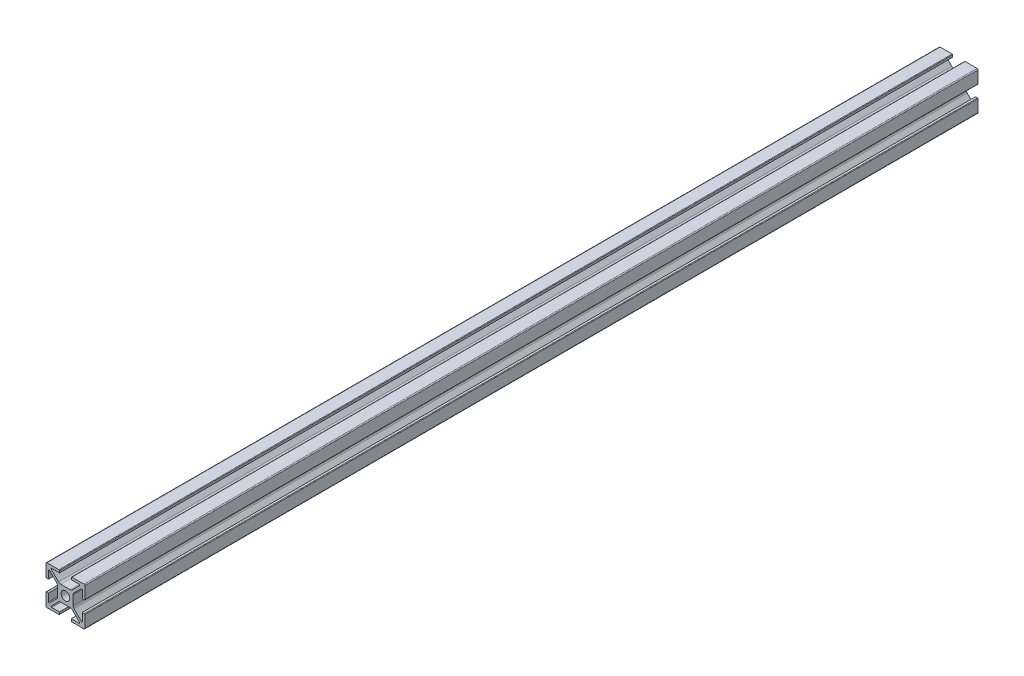
from build123d import *

# Parameters (mm, degrees)
ESBO_O11_R                                   = 2.25
QUADRADO_PF20_21_PERFIL_2020_T_SLOT_6M_DEPTH = 460


with BuildPart() as part:
    # Esboço11 → Quadrado PF20-21 - PERFIL 2020 T-SLOT 6MM(1) (new body)
    with BuildSketch(Plane(origin=(0, 0, 0), x_dir=(0, -1, 0), z_dir=(0, 0, 1))):
        with BuildLine():
            Line((8.187867966, -7.26862915), (4.439339828, -3.520101013))
            ThreePointArc((4.439339828, -3.520101013), (4.114180701, -3.033465989), (4, -2.459440841))
            Line((4, -2.459440841), (4, 2.459440841))
            ThreePointArc((4, 2.459440841), (4.114180701, 3.033465989), (4.439339828, 3.520101013))
            Line((4.439339828, 3.520101013), (8.187867966, 7.26862915))
            ThreePointArc((8.187867966, 7.26862915), (8.51480503, 7.333660975), (8.7, 7.056497116))
            Line((8.7, 7.056497116), (8.7, 3.05))
            Line((8.7, 3.05), (9.7, 3.05))
            ThreePointArc((9.7, 3.05), (9.912132034, 3.137867966), (10, 3.35))
            Line((10, 3.35), (10, 9.5))
            ThreePointArc((10, 9.5), (9.853553391, 9.853553391), (9.5, 10))
            Line((9.5, 10), (3.35, 10))
            ThreePointArc((3.35, 10), (3.137867966, 9.912132034), (3.05, 9.7))
            Line((3.05, 9.7), (3.05, 8.7))
            Line((3.05, 8.7), (7.056497116, 8.7))
            ThreePointArc((7.056497116, 8.7), (7.333660975, 8.51480503), (7.26862915, 8.187867966))
            Line((7.26862915, 8.187867966), (3.520101013, 4.439339828))
            ThreePointArc((3.520101013, 4.439339828), (3.033465989, 4.114180701), (2.459440841, 4))
            Line((2.459440841, 4), (-2.459440841, 4))
            ThreePointArc((-2.459440841, 4), (-3.033465989, 4.114180701), (-3.520101013, 4.439339828))
            Line((-3.520101013, 4.439339828), (-7.26862915, 8.187867966))
            ThreePointArc((-7.26862915, 8.187867966), (-7.333660975, 8.51480503), (-7.056497116, 8.7))
            Line((-7.056497116, 8.7), (-3.05, 8.7))
            Line((-3.05, 8.7), (-3.05, 9.7))
            ThreePointArc((-3.05, 9.7), (-3.137867966, 9.912132034), (-3.35, 10))
            Line((-3.35, 10), (-9.5, 10))
            ThreePointArc((-9.5, 10), (-9.853553391, 9.853553391), (-10, 9.5))
            Line((-10, 9.5), (-10, 3.35))
            ThreePointArc((-10, 3.35), (-9.912132034, 3.137867966), (-9.7, 3.05))
            Line((-9.7, 3.05), (-8.7, 3.05))
            Line((-8.7, 3.05), (-8.7, 7.056497116))
            ThreePointArc((-8.7, 7.056497116), (-8.51480503, 7.333660975), (-8.187867966, 7.26862915))
            Line((-8.187867966, 7.26862915), (-4.439339828, 3.520101013))
            ThreePointArc((-4.439339828, 3.520101013), (-4.114180701, 3.033465989), (-4, 2.459440841))
            Line((-4, 2.459440841), (-4, -2.459440841))
            ThreePointArc((-4, -2.459440841), (-4.114180701, -3.033465989), (-4.439339828, -3.520101013))
            Line((-4.439339828, -3.520101013), (-8.187867966, -7.26862915))
            ThreePointArc((-8.187867966, -7.26862915), (-8.51480503, -7.333660975), (-8.7, -7.056497116))
            Line((-8.7, -7.056497116), (-8.7, -3.05))
            Line((-8.7, -3.05), (-9.7, -3.05))
            ThreePointArc((-9.7, -3.05), (-9.912132034, -3.137867966), (-10, -3.35))
            Line((-10, -3.35), (-10, -9.5))
            ThreePointArc((-10, -9.5), (-9.853553391, -9.853553391), (-9.5, -10))
            Line((-9.5, -10), (-3.35, -10))
            ThreePointArc((-3.35, -10), (-3.137867966, -9.912132034), (-3.05, -9.7))
            Line((-3.05, -9.7), (-3.05, -8.7))
            Line((-3.05, -8.7), (-7.056497116, -8.7))
            ThreePointArc((-7.056497116, -8.7), (-7.333660975, -8.51480503), (-7.26862915, -8.187867966))
            Line((-7.26862915, -8.187867966), (-3.520101013, -4.439339828))
            ThreePointArc((-3.520101013, -4.439339828), (-3.033465989, -4.114180701), (-2.459440841, -4))
            Line((-2.459440841, -4), (2.459440841, -4))
            ThreePointArc((2.459440841, -4), (3.033465989, -4.114180701), (3.520101013, -4.439339828))
            Line((3.520101013, -4.439339828), (7.26862915, -8.187867966))
            ThreePointArc((7.26862915, -8.187867966), (7.333660975, -8.51480503), (7.056497116, -8.7))
            Line((7.056497116, -8.7), (3.05, -8.7))
            Line((3.05, -8.7), (3.05, -9.7))
            ThreePointArc((3.05, -9.7), (3.137867966, -9.912132034), (3.35, -10))
            Line((3.35, -10), (9.5, -10))
            ThreePointArc((9.5, -10), (9.853553391, -9.853553391), (10, -9.5))
            Line((10, -9.5), (10, -3.35))
            ThreePointArc((10, -3.35), (9.912132034, -3.137867966), (9.7, -3.05))
            Line((9.7, -3.05), (8.7, -3.05))
            Line((8.7, -3.05), (8.7, -7.056497116))
            ThreePointArc((8.7, -7.056497116), (8.51480503, -7.333660975), (8.187867966, -7.26862915))
        make_face()
        Circle(ESBO_O11_R, mode=Mode.SUBTRACT)
    extrude(amount=QUADRADO_PF20_21_PERFIL_2020_T_SLOT_6M_DEPTH)


solid = part.part
